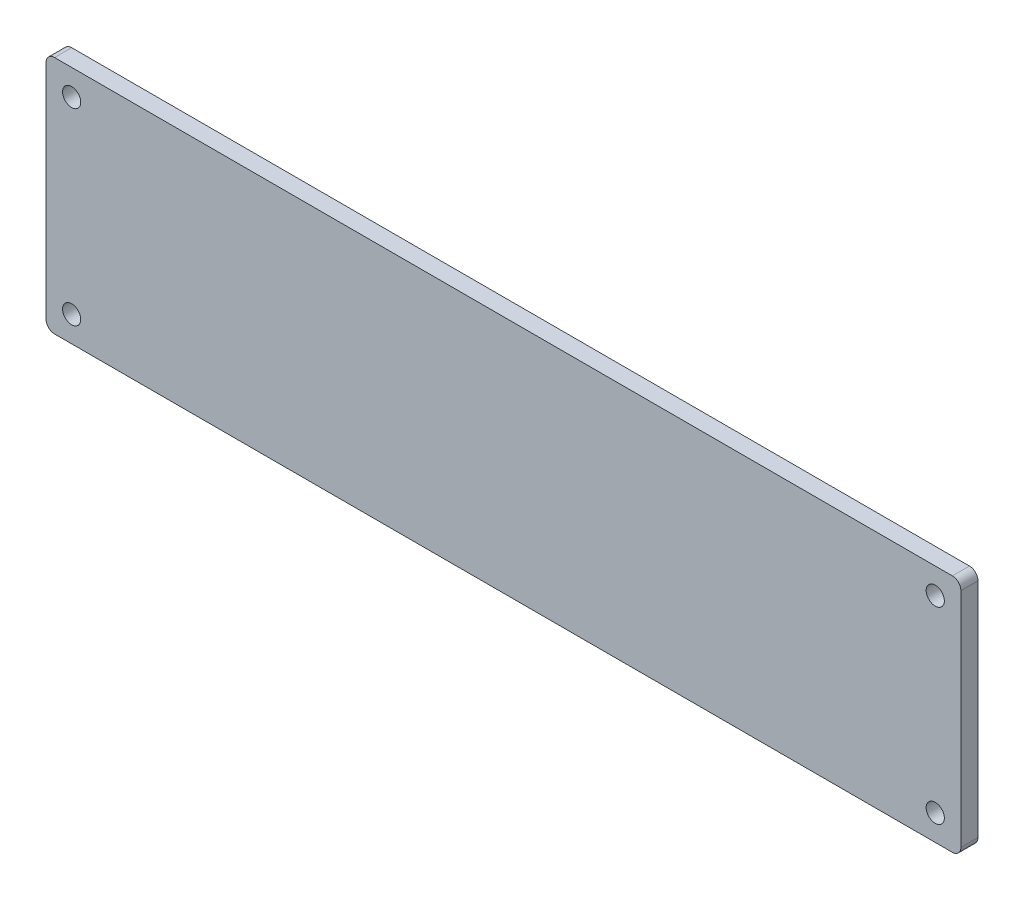
from build123d import *

# Parameters (mm, degrees)
SKETCH1_W               = 339.725
SKETCH1_H               = 88.9
BOSS_EXTRUDE1_DEPTH     = 6.35
F_1_4_CLEARANCE_HOLE1_D = 6.7564
FILLET1_R               = 3.175


with BuildPart() as part:
    # Sketch1 → Boss-Extrude1 (new body)
    with BuildSketch(Plane(origin=(0, 0, 0), x_dir=(-1, 0, 0), z_dir=(0, 0, -1))):
        Rectangle(SKETCH1_W, SKETCH1_H)
    extrude(amount=-BOSS_EXTRUDE1_DEPTH)

    # 1/4 Clearance Hole1 (through all)
    with Locations(Plane.XY.offset(6.35)):
        with Locations((-160.3375, 34.925), (-160.3375, -34.925), (160.3375, 34.925), (160.3375, -34.925)):
            Hole(F_1_4_CLEARANCE_HOLE1_D / 2)

    # Fillet1
    fillet1_edges = [part.edges().sort_by_distance(p)[0] for p in [
        (169.8625, 44.45, 3.175),
        (-169.8625, 44.45, 3.175),
        (-169.8625, -44.45, 3.175),
        (169.8625, -44.45, 3.175),
    ]]
    fillet(fillet1_edges, radius=FILLET1_R)


solid = part.part
